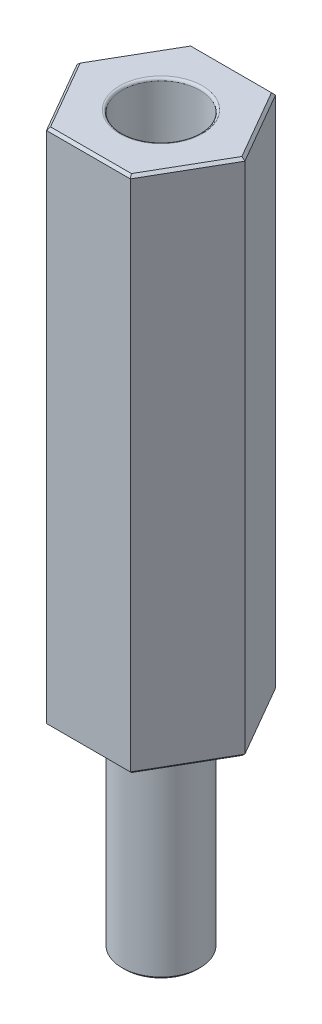
from build123d import *

# Parameters (mm, degrees)
BOSS_EXTRUDE1_DEPTH       = 20
SKETCH2_W                 = 1.5
SKETCH2_H                 = 8
F_3_0MM_DOWEL_HOLE1_D     = 3
F_3_0MM_DOWEL_HOLE1_DEPTH = 8
F_3_0MM_DOWEL_HOLE1_TIP   = 0.901290929
FILLET1_R                 = 0.1
CHAMFER1_SIZE             = 0.1


with BuildPart() as part:
    # Sketch1 → Boss-Extrude1 (new body)
    with BuildSketch(Plane.XZ):
        Polygon((-1.616580754, 2.8), (-3.233161507, 0), (-1.616580754, -2.8), (1.616580754, -2.8), (3.233161507, 0), (1.616580754, 2.8), align=None)
    extrude(amount=-BOSS_EXTRUDE1_DEPTH)

    # Sketch2 → Revolve1 (revolve)
    with BuildSketch(Plane.XY):
        with Locations((0.75, -4)):
            Rectangle(SKETCH2_W, SKETCH2_H)
    revolve(axis=Axis((0, 0, 0), (0, -1, 0)))

    # Ø3.0mm Dowel Hole1
    with Locations(Plane(origin=(0, 20, 0), x_dir=(1, 0, 0), z_dir=(0, 1, 0))):
        with Locations((0, 0)):
            Hole(F_3_0MM_DOWEL_HOLE1_D / 2, depth=F_3_0MM_DOWEL_HOLE1_DEPTH)
            with Locations((0, 0, -(F_3_0MM_DOWEL_HOLE1_DEPTH + F_3_0MM_DOWEL_HOLE1_TIP / 2))):  # 118° drill point
                Cone(0, F_3_0MM_DOWEL_HOLE1_D / 2, F_3_0MM_DOWEL_HOLE1_TIP, mode=Mode.SUBTRACT)

    # Fillet1
    fillet1_edges = [part.edges().sort_by_distance(p)[0] for p in [
        (1.5, 20, 0),
    ]]
    fillet(fillet1_edges, radius=FILLET1_R)

    # Chamfer1
    chamfer1_edges = [part.edges().sort_by_distance(p)[0] for p in [
        (-2.424871131, 20, -1.4),
        (0, 20, -2.8),
        (2.424871131, 20, -1.4),
        (2.424871131, 20, 1.4),
        (-1.5, -8, 0),
        (0, 20, 2.8),
        (2.424871131, 0, 1.4),
        (2.424871131, 0, -1.4),
        (0, 0, -2.8),
        (-2.424871131, 20, 1.4),
        (-2.424871131, 0, -1.4),
        (-2.424871131, 0, 1.4),
        (0, 0, 2.8),
    ]]
    chamfer(chamfer1_edges, length=CHAMFER1_SIZE)


solid = part.part
